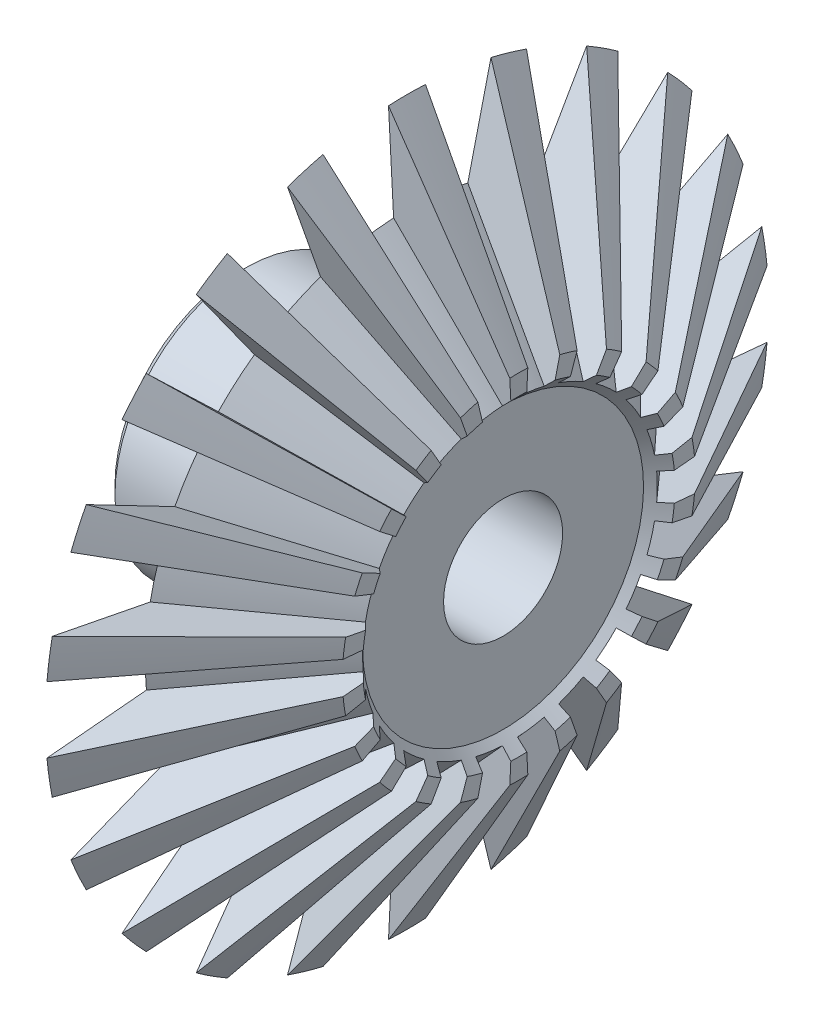
from build123d import *

# Parameters (mm, degrees)
CORTE_REVOLU_O2_ANGLE = 10.5
PADR_OCIRCULAR1_COUNT = 22


with BuildPart() as part:
    # Esboço1 → Revolução1 (revolve)
    with BuildSketch(Plane.XY, mode=Mode.PRIVATE) as revolu_o1_sk:
        with BuildLine():
            Line((0, 22.225), (104.772830684, 22.225))
            Line((104.772830684, 22.225), (104.772830684, 65.884431945))
            Line((104.772830684, 65.884431945), (63.025432751, 135))
            Line((63.025432751, 135), (63.025432751, 59.2125))
            ThreePointArc((63.025432751, 59.2125), (60.096500563, 52.141432188), (53.025432751, 49.2125))
            Line((53.025432751, 49.2125), (3.175, 49.2125))
            Line((3.175, 49.2125), (0, 46.0375))
            Line((0, 46.0375), (0, 22.225))
        make_face()
    revolve(revolu_o1_sk.sketch.rotate(Axis((0, 0, 0), (1, 0, 0)), 90), axis=Axis((0, 0, 0), (1, 0, 0)))  # turned: the seam where the file's is

    # Esboço3 → Corte-Revolução2 (revolve, symmetric, cut)
    with BuildSketch(Plane(origin=(0, 0, 0), x_dir=(1, 0, 0), z_dir=(0, 1, 0))) as corte_revolu_o2_sk:
        Polygon((104.772830684, 51.34699923), (63.025432751, 97.712181836), (63.025432751, 135), (111.527529929, 60.313319884), align=None)
    corte_revolu_o2 = revolve(axis=Axis((0, 0, 0), (1, 0, 0)), revolution_arc=CORTE_REVOLU_O2_ANGLE / 2, mode=Mode.SUBTRACT)
    corte_revolu_o2 = corte_revolu_o2 + revolve(corte_revolu_o2_sk.sketch, axis=Axis((0, 0, 0), (-1, 0, 0)), revolution_arc=CORTE_REVOLU_O2_ANGLE / 2, mode=Mode.SUBTRACT)

    # PadrãoCircular1: Corte-Revolução2 ×22 about axis
    padr_ocircular1_axis = Axis((0, 0, 0), (1, 0, 0))
    for i in range(1, PADR_OCIRCULAR1_COUNT):
        add(corte_revolu_o2.rotate(padr_ocircular1_axis, i * 360 / PADR_OCIRCULAR1_COUNT), mode=Mode.SUBTRACT)

    # Esboço2 → Corte-Revolução1 (revolve, cut)
    with BuildSketch(Plane.XY, mode=Mode.PRIVATE) as corte_revolu_o1_sk:
        Polygon((104.905562781, 58.449755058), (98.905562781, 52.449755058), (98.905562781, 18.901389006), (104.905562781, 18.901389006), align=None)
    revolve(corte_revolu_o1_sk.sketch.rotate(Axis((104.772830684, 0, 0), (-1, 0, 0)), 270), axis=Axis((104.772830684, 0, 0), (-1, 0, 0)), mode=Mode.SUBTRACT)  # turned: the seam where the file's is


solid = part.part
